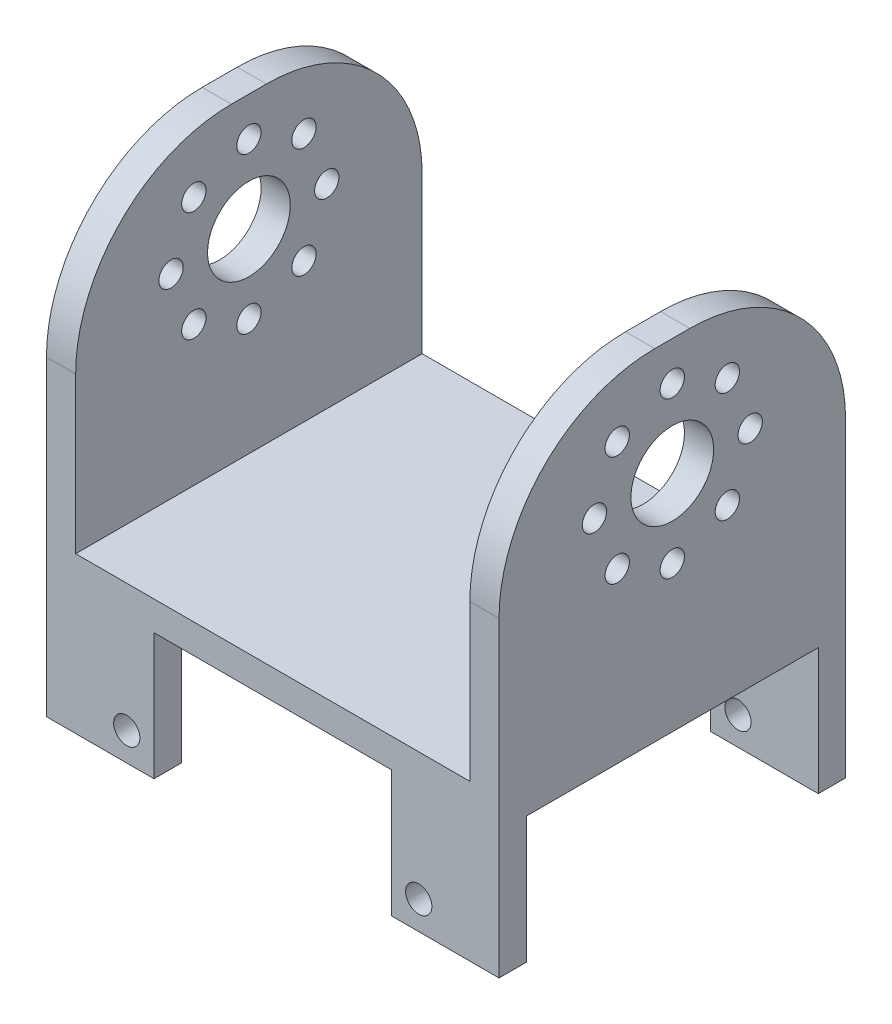
from build123d import *

# Parameters (mm, degrees)
SKETCH1_W                = 46.5
SKETCH1_H                = 35.6
BOSS_EXTRUDE1_DEPTH      = 2
SKETCH2_W                = 3
SKETCH2_H                = 35.6
BOSS_EXTRUDE2_DEPTH      = 50
SKETCH3_R                = 4.25
CUT_EXTRUDE1_DEPTH       = 47.5
SKETCH6_R                = 1.25
CUT_EXTRUDE3_DEPTH       = 47.5
FILLET5_R                = 16
SKETCH1_2_W              = 46.5
SKETCH1_2_H              = 35.6
CUT_EXTRUDE6_DEPTH       = 20
SKETCH8_W                = 46.5
SKETCH8_H                = 35.6
BOSS_EXTRUDE3_DEPTH      = 3
SKETCH9_W                = 35.6
SKETCH9_H                = 13
BOSS_EXTRUDE4_DEPTH      = 46.5
SKETCH12_W               = 24.4
SKETCH12_H               = 13
CUT_EXTRUDE9_DEPTH       = 36.6
SKETCH13_W               = 30
SKETCH13_H               = 13
CUT_EXTRUDE10_DEPTH      = 36.45
CUT_EXTRUDE10_DEPTH_BACK = 12.05
SKETCH15_R               = 1.35
CUT_EXTRUDE12_DEPTH      = 36.6


with BuildPart() as part:
    # Sketch1 → Boss-Extrude1 (new body)
    with BuildSketch(Plane(origin=(0, 0, 0), x_dir=(1, 0, 0), z_dir=(0, 1, 0))):
        Rectangle(SKETCH1_W, SKETCH1_H)
    extrude(amount=BOSS_EXTRUDE1_DEPTH)

    # Sketch2 → Boss-Extrude2 (add)
    with BuildSketch(Plane(origin=(0, 2, 0), x_dir=(1, 0, 0), z_dir=(0, 1, 0))):
        with Locations((-21.75, 0)):
            Rectangle(SKETCH2_W, SKETCH2_H)
        with Locations((21.75, 0)):
            Rectangle(SKETCH2_W, SKETCH2_H)
    extrude(amount=BOSS_EXTRUDE2_DEPTH)

    # Sketch3 → Cut-Extrude1 (cut, through all)
    with BuildSketch(Plane(origin=(23.25, 0, 0), x_dir=(0, 0, -1), z_dir=(1, 0, 0))):
        with Locations((0, 40)):
            Circle(SKETCH3_R)
    extrude(amount=-CUT_EXTRUDE1_DEPTH, mode=Mode.SUBTRACT)

    # Sketch6 → Cut-Extrude3 (cut, through all)
    with BuildSketch(Plane(origin=(23.25, 0, 0), x_dir=(0, 0, -1), z_dir=(1, 0, 0))):
        with Locations((0, 32)):
            Circle(SKETCH6_R)
        with Locations((-5.656854249, 34.343145751)):
            Circle(SKETCH6_R)
        with Locations((-8, 40)):
            Circle(SKETCH6_R)
        with Locations((-5.656854249, 45.656854249)):
            Circle(SKETCH6_R)
        with Locations((0, 48)):
            Circle(SKETCH6_R)
        with Locations((5.656854249, 45.656854249)):
            Circle(SKETCH6_R)
        with Locations((8, 40)):
            Circle(SKETCH6_R)
        with Locations((5.656854249, 34.343145751)):
            Circle(SKETCH6_R)
    extrude(amount=-CUT_EXTRUDE3_DEPTH, mode=Mode.SUBTRACT)

    # Fillet5
    fillet5_edges = [part.edges().sort_by_distance(p)[0] for p in [
        (-21.75, 52, 17.8),
        (-21.75, 52, -17.8),
        (21.75, 52, -17.8),
        (21.75, 52, 17.8),
    ]]
    fillet(fillet5_edges, radius=FILLET5_R)

    # Sketch1_2 → Cut-Extrude6 (cut)
    with BuildSketch(Plane(origin=(0, 0, 0), x_dir=(1, 0, 0), z_dir=(0, 1, 0))):
        Rectangle(SKETCH1_2_W, SKETCH1_2_H)
    extrude(amount=CUT_EXTRUDE6_DEPTH, mode=Mode.SUBTRACT)

    # Sketch8 → Boss-Extrude3 (add)
    with BuildSketch(Plane.XZ.offset(-20)):
        Rectangle(SKETCH8_W, SKETCH8_H)
    extrude(amount=BOSS_EXTRUDE3_DEPTH)

    # Sketch9 → Boss-Extrude4 (add)
    with BuildSketch(Plane(origin=(23.25, 0, 0), x_dir=(0, 0, -1), z_dir=(1, 0, 0))):
        with Locations((0, 10.5)):
            Rectangle(SKETCH9_W, SKETCH9_H)
    extrude(amount=-BOSS_EXTRUDE4_DEPTH)

    # Sketch12 → Cut-Extrude9 (cut, through all)
    with BuildSketch(Plane(origin=(0, 0, -17.8), x_dir=(-1, 0, 0), z_dir=(0, 0, -1))):
        with Locations((0, 10.5)):
            Rectangle(SKETCH12_W, SKETCH12_H)
    extrude(amount=-CUT_EXTRUDE9_DEPTH, mode=Mode.SUBTRACT)

    # Sketch13 → Cut-Extrude10 (cut, two sides)
    with BuildSketch(Plane.ZY.offset(-12.2)) as cut_extrude10_sk:
        with Locations((0, 10.5)):
            Rectangle(SKETCH13_W, SKETCH13_H)
    extrude(amount=CUT_EXTRUDE10_DEPTH, mode=Mode.SUBTRACT)
    extrude(cut_extrude10_sk.sketch, amount=-CUT_EXTRUDE10_DEPTH_BACK, mode=Mode.SUBTRACT)

    # Sketch15 → Cut-Extrude12 (cut, through all)
    with BuildSketch(Plane(origin=(0, 0, -17.8), x_dir=(-1, 0, 0), z_dir=(0, 0, -1))):
        with Locations((-15, 6.9)):
            Circle(SKETCH15_R)
        with Locations((15, 6.9)):
            Circle(SKETCH15_R)
    extrude(amount=-CUT_EXTRUDE12_DEPTH, mode=Mode.SUBTRACT)


solid = part.part
